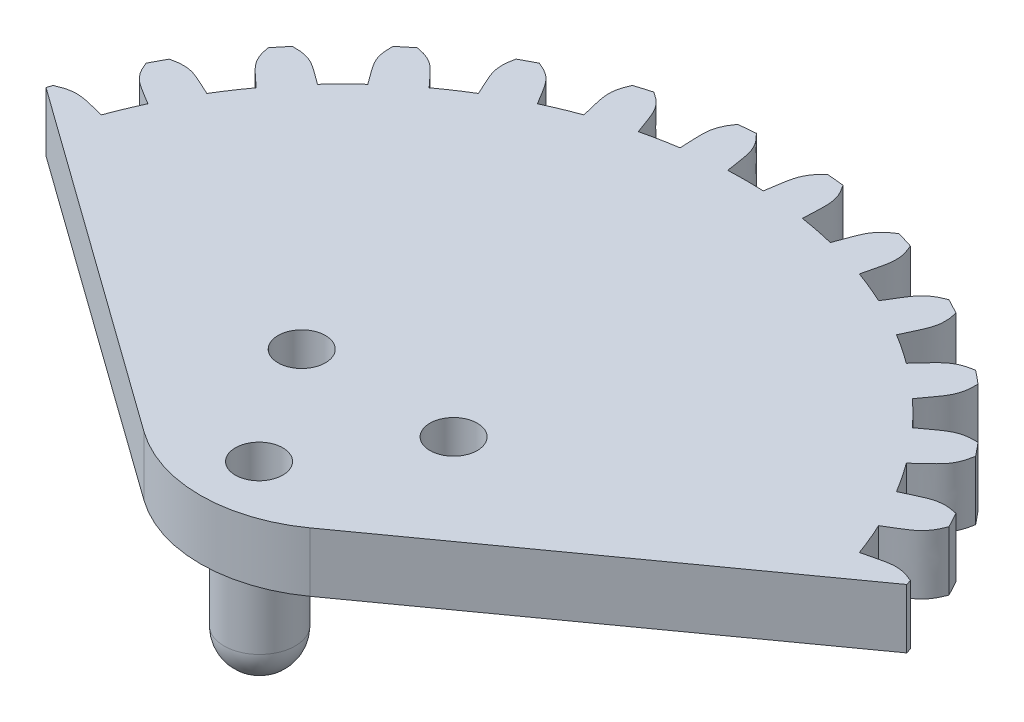
from build123d import *

# Parameters (mm, degrees)
BOSS_EXTRUDE1_DEPTH = 2.5
SKETCH2_R           = 0.25
BOSS_EXTRUDE2_DEPTH = 0.2
CUT_EXTRUDE2_DEPTH  = 3.5
CIRPATTERN1_COUNT   = 32
SKETCH6_R           = 1
CUT_EXTRUDE3_DEPTH  = 2
SKETCH7_R           = 1.5
BOSS_EXTRUDE3_DEPTH = 5
FILLET1_R           = 1.5


with BuildPart() as part:
    # Sketch1 → Boss-Extrude1 (new body)
    with BuildSketch(Plane(origin=(0, 0, 0), x_dir=(1, 0, 0), z_dir=(0, 1, 0))):
        with BuildLine():
            Line((-18.144509792, 5.637088291), (-3.498467254, -4.874497602))
            ThreePointArc((-3.498467254, -4.874497602), (0, -6), (3.498467254, -4.874497602))
            Line((3.498467254, -4.874497602), (18.144509792, 5.637088291))
            ThreePointArc((18.144509792, 5.637088291), (0, 19), (-18.144509792, 5.637088291))
        make_face()
    extrude(amount=BOSS_EXTRUDE1_DEPTH)

    # Sketch2 → Boss-Extrude2 (add)
    with BuildSketch(Plane.XZ):
        Circle(SKETCH2_R)
    extrude(amount=BOSS_EXTRUDE2_DEPTH)

    # Sketch4 → Cut-Extrude2 (cut)
    with BuildSketch(Plane(origin=(0, 2.5, 0), x_dir=(1, 0, 0), z_dir=(0, 1, 0))):
        with BuildLine():
            ThreePointArc((-0.75, 16.983447824), (0, 17), (0.75, 16.983447824))
            add(Edge.make_bspline(
                [(1.5, 18.940696925), (0.862132602, 18.342740151), (0.921198616, 17.96381227), (0.75, 16.983447824)],
                knots=[0, 0, 0, 0, 1, 1, 1, 1], degree=3))
            ThreePointArc((1.5, 18.940696925), (0, 19), (-1.5, 18.940696925))
            add(Edge.make_bspline(
                [(-1.5, 18.940696925), (-0.862132602, 18.342740151), (-0.921198616, 17.96381227), (-0.75, 16.983447824)],
                knots=[0, 0, 0, 0, 1, 1, 1, 1], degree=3))
        make_face()
    cut_extrude2 = extrude(amount=-CUT_EXTRUDE2_DEPTH, mode=Mode.SUBTRACT)

    # CirPattern1: Cut-Extrude2 ×32 about axis
    cirpattern1_axis = Axis((0, 0, 0), (0, 1, 0))
    for i in range(1, CIRPATTERN1_COUNT):
        add(cut_extrude2.rotate(cirpattern1_axis, i * 360 / CIRPATTERN1_COUNT), mode=Mode.SUBTRACT)

    # Sketch6 → Cut-Extrude3 (cut)
    with BuildSketch(Plane(origin=(0, 2.5, 0), x_dir=(1, 0, 0), z_dir=(0, 1, 0))):
        with Locations((-3.201562119, 1.475)):
            Circle(SKETCH6_R)
        with Locations((3.201562119, 1.475)):
            Circle(SKETCH6_R)
        with Locations((0, -3.525)):
            Circle(SKETCH6_R)
    extrude(amount=-CUT_EXTRUDE3_DEPTH, mode=Mode.SUBTRACT)

    # Sketch7 → Boss-Extrude3 (add)
    with BuildSketch(Plane.XZ):
        with Locations((0, 3.5)):
            Circle(SKETCH7_R)
    extrude(amount=BOSS_EXTRUDE3_DEPTH)

    # Fillet1
    fillet1_edges = [part.edges().sort_by_distance(p)[0] for p in [
        (-1.5, -5, 3.5),
    ]]
    fillet(fillet1_edges, radius=FILLET1_R)


solid = part.part
